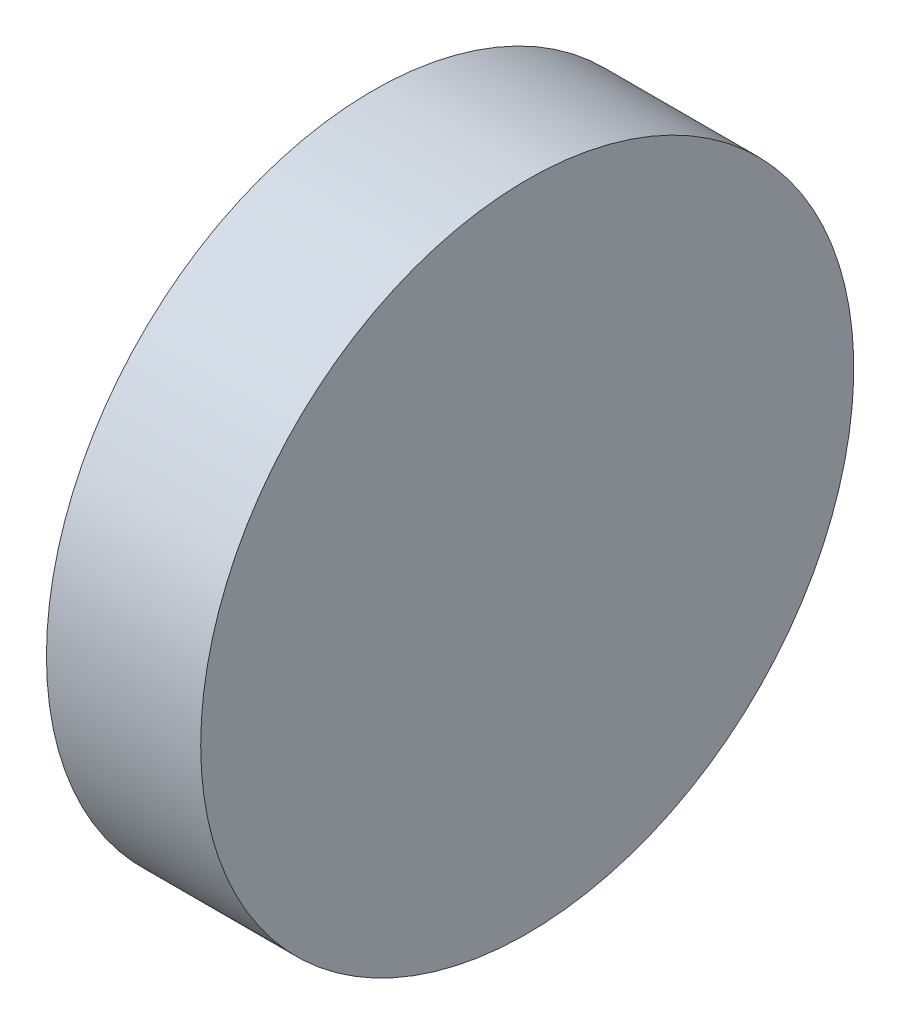
from build123d import *

# Parameters (mm, degrees)
SKETCH_1_W = 6
SKETCH_1_H = 12.7


with BuildPart() as part:
    # 草图1 → 旋转1 (revolve)
    with BuildSketch(Plane.XY, mode=Mode.PRIVATE) as revolve_1_sk:
        with Locations((271.816825871, 83.643179349)):
            Rectangle(SKETCH_1_W, SKETCH_1_H)
    revolve(revolve_1_sk.sketch.rotate(Axis((263.09327497, 77.293179349, 0), (1, 0, 0)), 90), axis=Axis((263.09327497, 77.293179349, 0), (1, 0, 0)))  # turned: the seam where the file's is


solid = part.part
